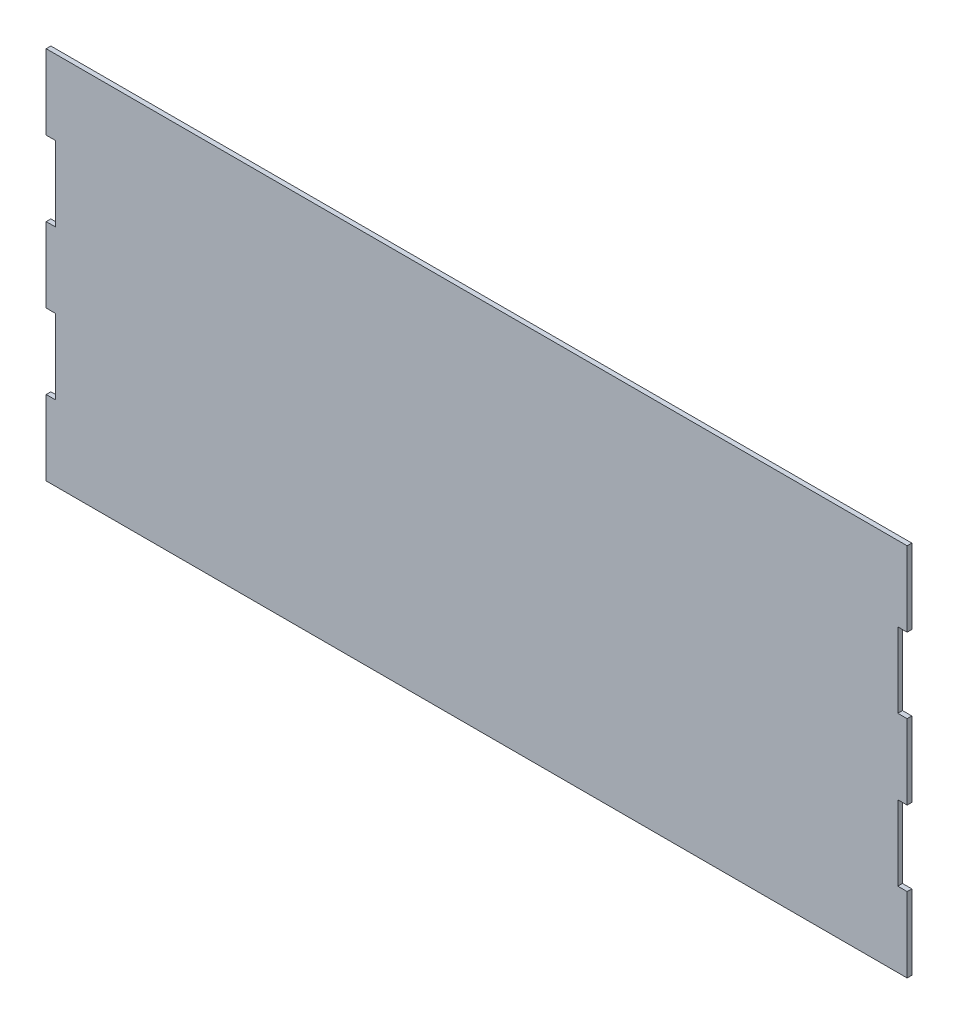
from build123d import *

# Parameters (mm, degrees)
BOSS_EXTRUDE1_DEPTH = 3.175


with BuildPart() as part:
    # Sketch1 → Boss-Extrude1 (new body)
    with BuildSketch(Plane.XY):
        Polygon((584.2, 101.6), (577.85, 101.6), (577.85, 50.8), (584.2, 50.8), (584.2, 0), (0, 0), (0, 50.8), (6.35, 50.8), (6.35, 101.6), (0, 101.6), (0, 152.4), (6.35, 152.4), (6.35, 203.2), (0, 203.2), (0, 254), (584.2, 254), (584.2, 203.2), (577.85, 203.2), (577.85, 152.4), (584.2, 152.4), align=None)
    extrude(amount=BOSS_EXTRUDE1_DEPTH)


solid = part.part
